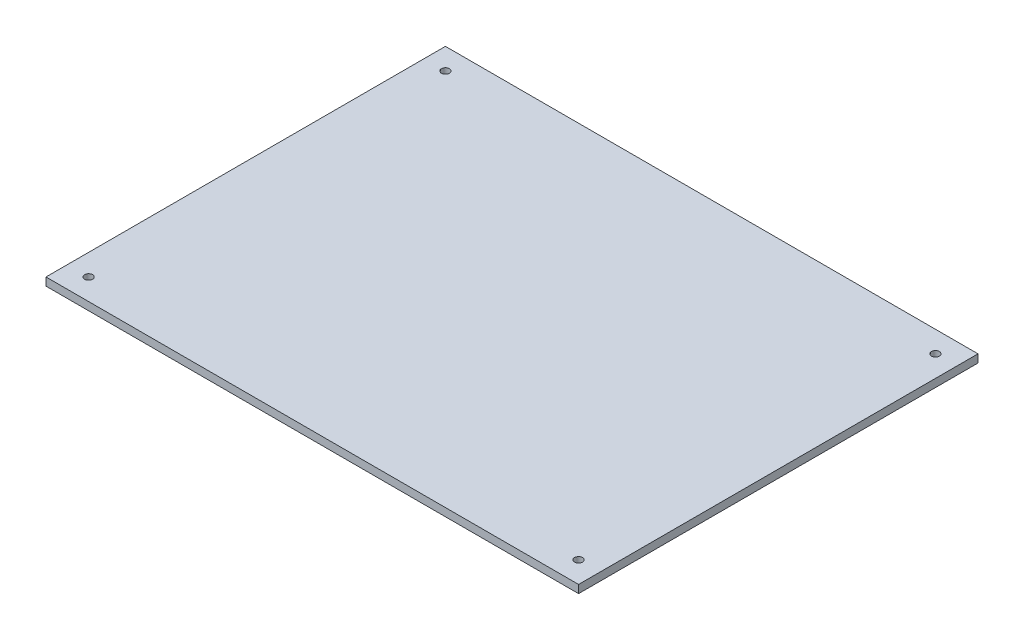
from build123d import *

# Parameters (mm, degrees)
SKETCH_1_W      = 200
SKETCH_1_H      = 150
SKETCH_1_R      = 1.5
EXTRUDE_1_DEPTH = 3


with BuildPart() as part:
    # 草圖1 → 填料-伸長1 (new body)
    with BuildSketch(Plane(origin=(0, 0, 0), x_dir=(1, 0, 0), z_dir=(0, 1, 0))):
        with Locations((-4.089536972, 8.522727273)):
            Rectangle(SKETCH_1_W, SKETCH_1_H)
        with Locations((-96.089536972, 75.522727273)):
            Circle(SKETCH_1_R, mode=Mode.SUBTRACT)
        with Locations((-96.089536972, -58.477272727)):
            Circle(SKETCH_1_R, mode=Mode.SUBTRACT)
        with Locations((87.910463028, -58.477272727)):
            Circle(SKETCH_1_R, mode=Mode.SUBTRACT)
        with Locations((87.910463028, 75.522727273)):
            Circle(SKETCH_1_R, mode=Mode.SUBTRACT)
    extrude(amount=EXTRUDE_1_DEPTH)


solid = part.part
